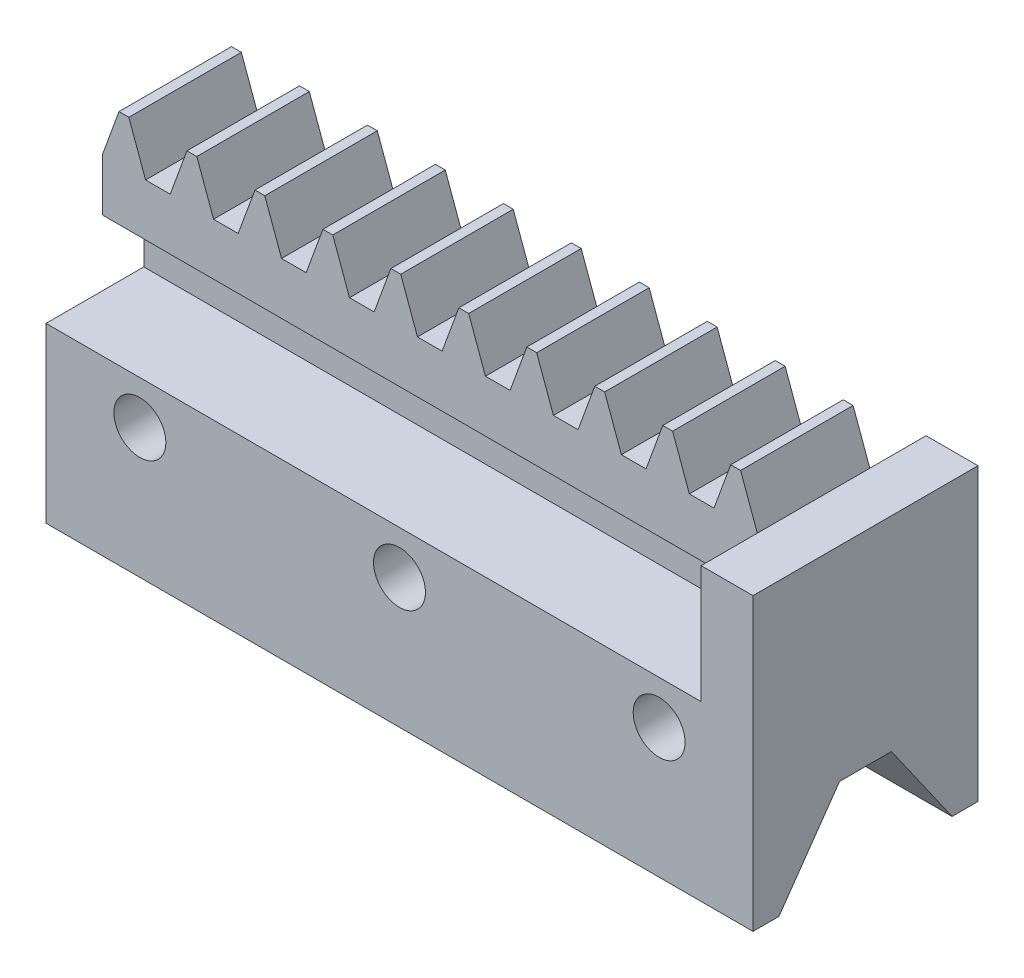
from build123d import *

# Parameters (mm, degrees)
ESQUISSE1_R             = 2.5
BOSS_EXTRU_1_DEPTH      = 1
BOSS_EXTRU_2_DEPTH      = 6.5
ESQUISSE3_R             = 14.137419556
ENL_V_MAT_EXTRU_1_DEPTH = 1
ESQUISSE4_W             = 37.844594902
ESQUISSE4_H             = 1.7
BOSS_EXTRU_3_DEPTH      = 3.8
ESQUISSE5_W             = 37.844594902
ESQUISSE5_H             = 13
BOSS_EXTRU_4_DEPTH      = 5
ESQUISSE6_W             = 13
ESQUISSE6_H             = 11.8
BOSS_EXTRU_5_DEPTH      = 3
BOSS_EXTRU_6_DEPTH      = 40.844595
ESQUISSE8_R             = 1.5
ENL_V_MAT_EXTRU_2_DEPTH = 14


with BuildPart() as part:
    # Esquisse1 → Boss.-Extru.1 (new body)
    with BuildSketch(Plane.XY):
        with BuildLine():
            ThreePointArc((-2.797532396, 7.349311298), (-3.009326841, 7.265157674), (-3.218593728, 7.174901984))
            ThreePointArc((-3.218593728, 7.174901984), (-3.518823735, 7.161602241), (-3.746621491, 7.357620412))
            ThreePointArc((-3.746621491, 7.357620412), (-4.480939546, 8.300763177), (-5.498824516, 8.927382256))
            ThreePointArc((-5.498824516, 8.927382256), (-5.825153893, 8.717958885), (-6.143516706, 8.496612707))
            ThreePointArc((-6.143516706, 8.496612707), (-5.954123878, 7.316412877), (-5.363784935, 6.277066345))
            ThreePointArc((-5.363784935, 6.277066345), (-5.269862186, 5.991595754), (-5.397042596, 5.719308987))
            ThreePointArc((-5.397042596, 5.719308987), (-5.560510951, 5.560510951), (-5.719308987, 5.397042596))
            ThreePointArc((-5.719308987, 5.397042596), (-5.991595754, 5.269862186), (-6.277066345, 5.363784935))
            ThreePointArc((-6.277066345, 5.363784935), (-7.316412877, 5.954123878), (-8.496612707, 6.143516706))
            ThreePointArc((-8.496612707, 6.143516706), (-8.717958885, 5.825153893), (-8.927382256, 5.498824516))
            ThreePointArc((-8.927382256, 5.498824516), (-8.300763177, 4.480939546), (-7.357620412, 3.746621491))
            ThreePointArc((-7.357620412, 3.746621491), (-7.161602241, 3.518823735), (-7.174901984, 3.218593728))
            ThreePointArc((-7.174901984, 3.218593728), (-7.265157674, 3.009326841), (-7.349311298, 2.797532396))
            ThreePointArc((-7.349311298, 2.797532396), (-7.552201634, 2.575833384), (-7.851884749, 2.553361824))
            ThreePointArc((-7.851884749, 2.553361824), (-9.038028671, 2.701023192), (-10.200868635, 2.424356428))
            ThreePointArc((-10.200868635, 2.424356428), (-10.283533665, 2.045522026), (-10.352134785, 1.663890139))
            ThreePointArc((-10.352134785, 1.663890139), (-9.383686529, 0.963283789), (-8.231324879, 0.645787478))
            ThreePointArc((-8.231324879, 0.645787478), (-7.963053276, 0.510342701), (-7.860447586, 0.22787675))
            ThreePointArc((-7.860447586, 0.22787675), (-7.86375, 0), (-7.860447586, -0.22787675))
            ThreePointArc((-7.860447586, -0.22787675), (-7.963053276, -0.510342701), (-8.231324879, -0.645787478))
            ThreePointArc((-8.231324879, -0.645787478), (-9.383686529, -0.963283789), (-10.352134785, -1.663890139))
            ThreePointArc((-10.352134785, -1.663890139), (-10.283533665, -2.045522026), (-10.200868635, -2.424356428))
            ThreePointArc((-10.200868635, -2.424356428), (-9.038028671, -2.701023192), (-7.851884749, -2.553361824))
            ThreePointArc((-7.851884749, -2.553361824), (-7.552201634, -2.575833384), (-7.349311298, -2.797532396))
            ThreePointArc((-7.349311298, -2.797532396), (-7.265157674, -3.009326841), (-7.174901984, -3.218593728))
            ThreePointArc((-7.174901984, -3.218593728), (-7.161602241, -3.518823735), (-7.357620412, -3.746621491))
            ThreePointArc((-7.357620412, -3.746621491), (-8.300763177, -4.480939546), (-8.927382256, -5.498824516))
            ThreePointArc((-8.927382256, -5.498824516), (-8.717958885, -5.825153893), (-8.496612707, -6.143516706))
            ThreePointArc((-8.496612707, -6.143516706), (-7.316412877, -5.954123878), (-6.277066345, -5.363784935))
            ThreePointArc((-6.277066345, -5.363784935), (-5.991595754, -5.269862186), (-5.719308987, -5.397042596))
            ThreePointArc((-5.719308987, -5.397042596), (-5.560510951, -5.560510951), (-5.397042596, -5.719308987))
            ThreePointArc((-5.397042596, -5.719308987), (-5.269862186, -5.991595754), (-5.363784935, -6.277066345))
            ThreePointArc((-5.363784935, -6.277066345), (-5.954123878, -7.316412877), (-6.143516706, -8.496612707))
            ThreePointArc((-6.143516706, -8.496612707), (-5.825153893, -8.717958885), (-5.498824516, -8.927382256))
            ThreePointArc((-5.498824516, -8.927382256), (-4.480939546, -8.300763177), (-3.746621491, -7.357620412))
            ThreePointArc((-3.746621491, -7.357620412), (-3.518823735, -7.161602241), (-3.218593728, -7.174901984))
            ThreePointArc((-3.218593728, -7.174901984), (-3.009326841, -7.265157674), (-2.797532396, -7.349311298))
            ThreePointArc((-2.797532396, -7.349311298), (-2.575833384, -7.552201634), (-2.553361824, -7.851884749))
            ThreePointArc((-2.553361824, -7.851884749), (-2.701023192, -9.038028671), (-2.424356428, -10.200868635))
            ThreePointArc((-2.424356428, -10.200868635), (-2.045522026, -10.283533665), (-1.663890139, -10.352134785))
            ThreePointArc((-1.663890139, -10.352134785), (-0.963283789, -9.383686529), (-0.645787478, -8.231324879))
            ThreePointArc((-0.645787478, -8.231324879), (-0.510342701, -7.963053276), (-0.22787675, -7.860447586))
            ThreePointArc((-0.22787675, -7.860447586), (0, -7.86375), (0.22787675, -7.860447586))
            ThreePointArc((0.22787675, -7.860447586), (0.510342701, -7.963053276), (0.645787478, -8.231324879))
            ThreePointArc((0.645787478, -8.231324879), (0.963283789, -9.383686529), (1.663890139, -10.352134785))
            ThreePointArc((1.663890139, -10.352134785), (2.045522026, -10.283533665), (2.424356428, -10.200868635))
            ThreePointArc((2.424356428, -10.200868635), (2.701023192, -9.038028671), (2.553361824, -7.851884749))
            ThreePointArc((2.553361824, -7.851884749), (2.575833384, -7.552201634), (2.797532396, -7.349311298))
            ThreePointArc((2.797532396, -7.349311298), (3.009326841, -7.265157674), (3.218593728, -7.174901984))
            ThreePointArc((3.218593728, -7.174901984), (3.518823735, -7.161602241), (3.746621491, -7.357620412))
            ThreePointArc((3.746621491, -7.357620412), (4.480939546, -8.300763177), (5.498824516, -8.927382256))
            ThreePointArc((5.498824516, -8.927382256), (5.825153893, -8.717958885), (6.143516706, -8.496612707))
            ThreePointArc((6.143516706, -8.496612707), (5.954123878, -7.316412877), (5.363784935, -6.277066345))
            ThreePointArc((5.363784935, -6.277066345), (5.269862186, -5.991595754), (5.397042596, -5.719308987))
            ThreePointArc((5.397042596, -5.719308987), (5.560510951, -5.560510951), (5.719308987, -5.397042596))
            ThreePointArc((5.719308987, -5.397042596), (5.991595754, -5.269862186), (6.277066345, -5.363784935))
            ThreePointArc((6.277066345, -5.363784935), (7.316412877, -5.954123878), (8.496612707, -6.143516706))
            ThreePointArc((8.496612707, -6.143516706), (8.717958885, -5.825153893), (8.927382256, -5.498824516))
            ThreePointArc((8.927382256, -5.498824516), (8.300763177, -4.480939546), (7.357620412, -3.746621491))
            ThreePointArc((7.357620412, -3.746621491), (7.161602241, -3.518823735), (7.174901984, -3.218593728))
            ThreePointArc((7.174901984, -3.218593728), (7.265157674, -3.009326841), (7.349311298, -2.797532396))
            ThreePointArc((7.349311298, -2.797532396), (7.552201634, -2.575833384), (7.851884749, -2.553361824))
            ThreePointArc((7.851884749, -2.553361824), (9.038028671, -2.701023192), (10.200868635, -2.424356428))
            ThreePointArc((10.200868635, -2.424356428), (10.283533665, -2.045522026), (10.352134785, -1.663890139))
            ThreePointArc((10.352134785, -1.663890139), (9.383686529, -0.963283789), (8.231324879, -0.645787478))
            ThreePointArc((8.231324879, -0.645787478), (7.963053276, -0.510342701), (7.860447586, -0.22787675))
            ThreePointArc((7.860447586, -0.22787675), (7.86375, 0), (7.860447586, 0.22787675))
            ThreePointArc((7.860447586, 0.22787675), (7.963053276, 0.510342701), (8.231324879, 0.645787478))
            ThreePointArc((8.231324879, 0.645787478), (9.383686529, 0.963283789), (10.352134785, 1.663890139))
            ThreePointArc((10.352134785, 1.663890139), (10.283533665, 2.045522026), (10.200868635, 2.424356428))
            ThreePointArc((10.200868635, 2.424356428), (9.038028671, 2.701023192), (7.851884749, 2.553361824))
            ThreePointArc((7.851884749, 2.553361824), (7.552201634, 2.575833384), (7.349311298, 2.797532396))
            ThreePointArc((7.349311298, 2.797532396), (7.265157674, 3.009326841), (7.174901984, 3.218593728))
            ThreePointArc((7.174901984, 3.218593728), (7.161602241, 3.518823735), (7.357620412, 3.746621491))
            ThreePointArc((7.357620412, 3.746621491), (8.300763177, 4.480939546), (8.927382256, 5.498824516))
            ThreePointArc((8.927382256, 5.498824516), (8.717958885, 5.825153893), (8.496612707, 6.143516706))
            ThreePointArc((8.496612707, 6.143516706), (7.316412877, 5.954123878), (6.277066345, 5.363784935))
            ThreePointArc((6.277066345, 5.363784935), (5.991595754, 5.269862186), (5.719308987, 5.397042596))
            ThreePointArc((5.719308987, 5.397042596), (5.560510951, 5.560510951), (5.397042596, 5.719308987))
            ThreePointArc((5.397042596, 5.719308987), (5.269862186, 5.991595754), (5.363784935, 6.277066345))
            ThreePointArc((5.363784935, 6.277066345), (5.954123878, 7.316412877), (6.143516706, 8.496612707))
            ThreePointArc((6.143516706, 8.496612707), (5.825153893, 8.717958885), (5.498824516, 8.927382256))
            ThreePointArc((5.498824516, 8.927382256), (4.480939546, 8.300763177), (3.746621491, 7.357620412))
            ThreePointArc((3.746621491, 7.357620412), (3.518823735, 7.161602241), (3.218593728, 7.174901984))
            ThreePointArc((3.218593728, 7.174901984), (3.009326841, 7.265157674), (2.797532396, 7.349311298))
            ThreePointArc((2.797532396, 7.349311298), (2.575833384, 7.552201634), (2.553361824, 7.851884749))
            ThreePointArc((2.553361824, 7.851884749), (2.701023192, 9.038028671), (2.424356428, 10.200868635))
            ThreePointArc((2.424356428, 10.200868635), (2.045522026, 10.283533665), (1.663890139, 10.352134785))
            ThreePointArc((1.663890139, 10.352134785), (0.963283789, 9.383686529), (0.645787478, 8.231324879))
            ThreePointArc((0.645787478, 8.231324879), (0.510342701, 7.963053276), (0.22787675, 7.860447586))
            ThreePointArc((0.22787675, 7.860447586), (0, 7.86375), (-0.22787675, 7.860447586))
            ThreePointArc((-0.22787675, 7.860447586), (-0.510342701, 7.963053276), (-0.645787478, 8.231324879))
            ThreePointArc((-0.645787478, 8.231324879), (-0.963283789, 9.383686529), (-1.663890139, 10.352134785))
            ThreePointArc((-1.663890139, 10.352134785), (-2.045522026, 10.283533665), (-2.424356428, 10.200868635))
            ThreePointArc((-2.424356428, 10.200868635), (-2.701023192, 9.038028671), (-2.553361824, 7.851884749))
            ThreePointArc((-2.553361824, 7.851884749), (-2.575833384, 7.552201634), (-2.797532396, 7.349311298))
        make_face()
        Circle(ESQUISSE1_R, mode=Mode.SUBTRACT)
    extrude(amount=BOSS_EXTRU_1_DEPTH)

    # Esquisse2 → Boss.-Extru.2 (add)
    with BuildSketch(Plane.XY.offset(1)):
        Polygon((0.284655009, -8), (1.251359951, -10.656), (2.675515049, -10.656), (3.642219991, -8), (4.211530009, -8), (5.178234951, -10.656), (6.602390049, -10.656), (7.569094991, -8), (8.138405009, -8), (9.105109951, -10.656), (10.529265049, -10.656), (11.495969991, -8), (12.065280009, -8), (13.031984951, -10.656), (14.456140049, -10.656), (15.422844991, -8), (15.992155009, -8), (16.958859951, -10.656), (18.383015049, -10.656), (19.349719991, -8), (19.919030009, -8), (20.885734951, -10.656), (22.309890049, -10.656), (23.276594991, -8), (23.845905009, -8), (24.812609951, -10.656), (26.236765049, -10.656), (27.203469991, -8), (27.772780009, -8), (28.739484951, -10.656), (30.163640049, -10.656), (31.130344991, -8), (31.699655009, -8), (32.666359951, -10.656), (34.090515049, -10.656), (35.057219991, -8), (35.626530009, -8), (36.593234951, -10.656), (36.593234951, -13.656), (-1.251359951, -13.656), (-1.251359951, -10.656), (-0.284655009, -8), align=None)
    extrude(amount=BOSS_EXTRU_2_DEPTH)

    # Esquisse3 → Enlèv. mat.-Extru.1 (cut)
    with BuildSketch(Plane(origin=(0, 0, 0), x_dir=(-1, 0, 0), z_dir=(0, 0, -1))):
        Circle(ESQUISSE3_R)
    extrude(amount=-ENL_V_MAT_EXTRU_1_DEPTH, mode=Mode.SUBTRACT)

    # Esquisse4 → Boss.-Extru.3 (add)
    with BuildSketch(Plane.XZ.offset(13.656)):
        with Locations((17.6709375, 4.25)):
            Rectangle(ESQUISSE4_W, ESQUISSE4_H)
    extrude(amount=BOSS_EXTRU_3_DEPTH)

    # Esquisse5 → Boss.-Extru.4 (add)
    with BuildSketch(Plane.XZ.offset(17.456)):
        with Locations((17.6709375, 4.25)):
            Rectangle(ESQUISSE5_W, ESQUISSE5_H)
    extrude(amount=BOSS_EXTRU_4_DEPTH)

    # Esquisse6 → Boss.-Extru.5 (add)
    with BuildSketch(Plane(origin=(36.593234951, 0, 0), x_dir=(0, 0, -1), z_dir=(1, 0, 0))):
        with Locations((-4.25, -16.556)):
            Rectangle(ESQUISSE6_W, ESQUISSE6_H)
    extrude(amount=BOSS_EXTRU_5_DEPTH)

    # Esquisse7 → Boss.-Extru.6 (add, through all)
    with BuildSketch(Plane.ZY.offset(1.251359951)):
        Polygon((-2.25, -22.456), (-2.25, -27.456), (-0.75, -27.456), (2.751037691, -22.456), align=None)
        Polygon((9.25, -27.456), (5.748962309, -22.456), (10.75, -22.456), (10.75, -27.456), align=None)
    extrude(amount=-BOSS_EXTRU_6_DEPTH)

    # Esquisse8 → Enlèv. mat.-Extru.2 (cut, through all)
    with BuildSketch(Plane(origin=(0, 0, -2.25), x_dir=(-1, 0, 0), z_dir=(0, 0, -1))):
        with Locations((-34.1709375, -19.956)):
            Circle(ESQUISSE8_R)
        with Locations((-4.1709375, -19.956)):
            Circle(ESQUISSE8_R)
        with Locations((-19.1709375, -19.956)):
            Circle(ESQUISSE8_R)
    extrude(amount=-ENL_V_MAT_EXTRU_2_DEPTH, mode=Mode.SUBTRACT)


solid = part.part
